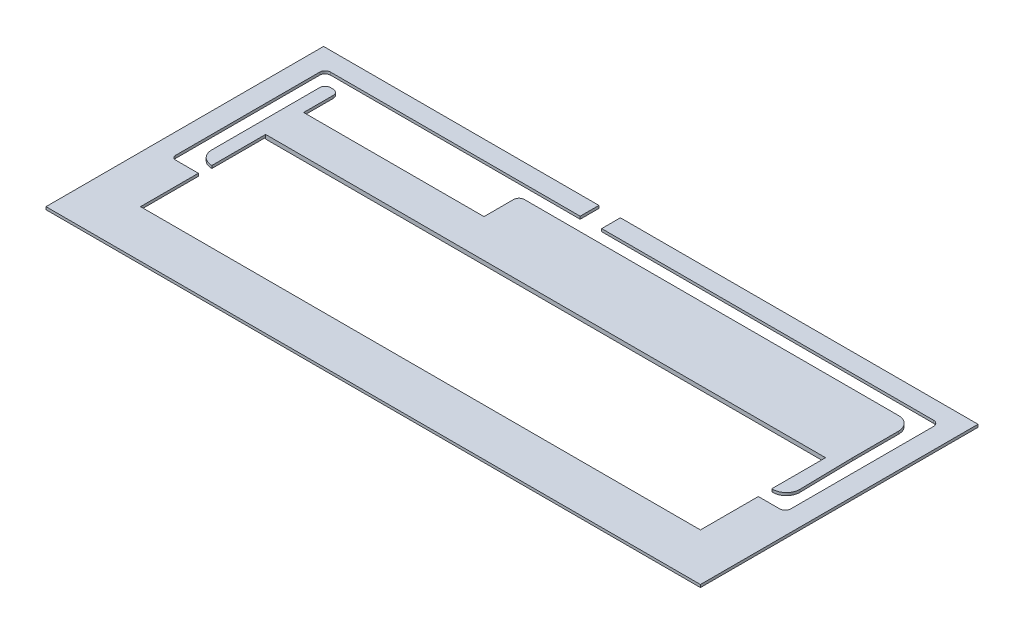
from build123d import *

# Parameters (mm, degrees)
CROQUIS1_W              = 486.2
CROQUIS1_H              = 206.2
CROQUIS1_W_2            = 480
CROQUIS1_H_2            = 200
SALIENTE_EXTRUIR1_DEPTH = 12
CROQUIS3_W              = 486.2
CROQUIS3_H              = 206.2
CROQUIS3_W_2            = 480
CROQUIS3_H_2            = 200
CORTAR_EXTRUIR1_DEPTH   = 5
CORTAR_EXTRUIR3_DEPTH   = 8
CROQUIS4_W              = 20
CROQUIS4_H              = 6
CORTAR_EXTRUIR4_DEPTH   = 3
CORTAR_EXTRUIR5_DEPTH   = 2
CROQUIS7_W              = 721.947089947
CROQUIS7_H              = 359.419856831
CORTAR_EXTRUIR6_DEPTH   = 10
CROQUIS8_W              = 416
CROQUIS8_H              = 96
CORTAR_EXTRUIR7_DEPTH   = 10
CROQUIS9_W              = 531.904745737
CROQUIS9_H              = 246.353411826
CORTAR_EXTRUIR9_DEPTH   = 10
CROQUIS10_W             = 531.904745737
CROQUIS10_H             = 246.353411826
CORTAR_EXTRUIR10_DEPTH  = 10
CROQUIS11_W             = 531.904745737
CROQUIS11_H             = 246.353411826
CORTAR_EXTRUIR11_DEPTH  = 10
CROQUIS12_W             = 416
CROQUIS12_H             = 3.047420062
SALIENTE_EXTRUIR2_DEPTH = 3


with BuildPart() as part:
    # Croquis1 → Saliente-Extruir1 (new body)
    with BuildSketch(Plane(origin=(0, 0, 0), x_dir=(1, 0, 0), z_dir=(0, 1, 0))):
        with Locations((240, 100)):
            Rectangle(CROQUIS1_W, CROQUIS1_H)
        with Locations((240, 100)):
            Rectangle(CROQUIS1_W_2, CROQUIS1_H_2, mode=Mode.SUBTRACT)
        with Locations((240, 100)):
            Rectangle(CROQUIS1_W_2, CROQUIS1_H_2)
    extrude(amount=SALIENTE_EXTRUIR1_DEPTH)

    # Croquis3 → Cortar-Extruir1 (cut)
    with BuildSketch(Plane(origin=(0, 12, 0), x_dir=(1, 0, 0), z_dir=(0, 1, 0))):
        with Locations((240, 100)):
            Rectangle(CROQUIS3_W, CROQUIS3_H)
        with Locations((240, 100)):
            Rectangle(CROQUIS3_W_2, CROQUIS3_H_2, mode=Mode.SUBTRACT)
    extrude(amount=-CORTAR_EXTRUIR1_DEPTH, mode=Mode.SUBTRACT)

    # Croquis2 → Cortar-Extruir3 (cut)
    with BuildSketch(Plane(origin=(0, 12, 0), x_dir=(1, 0, 0), z_dir=(0, 1, 0))):
        with BuildLine():
            ThreePointArc((16, 189.1902066), (13.171572875, 188.018633725), (12, 185.1902066))
            Line((12, 185.1902066), (12, 78))
            ThreePointArc((12, 78), (12.878679656, 75.878679656), (15, 75))
            Line((15, 75), (32, 75))
            Line((32, 75), (32, 32))
            Line((32, 32), (448, 32))
            Line((448, 32), (448, 75))
            Line((448, 75), (464, 75))
            ThreePointArc((464, 75), (466.828427125, 76.171572875), (468, 79))
            Line((468, 79), (468, 185.1902066))
            ThreePointArc((468, 185.1902066), (466.828427125, 188.018633725), (464, 189.1902066))
            Line((464, 189.1902066), (217.424703227, 189.1902066))
            Line((217.424703227, 189.1902066), (217.424703227, 203.1))
            Line((217.424703227, 203.1), (201.44869327, 203.1))
            Line((201.44869327, 203.1), (201.44869327, 189.1902066))
            Line((201.44869327, 189.1902066), (16, 189.1902066))
        make_face()
        with BuildLine():
            Line((32, 85), (31.963588191, 85))
            ThreePointArc((31.963588191, 85), (24.892520379, 87.928932188), (21.963588191, 95))
            Line((21.963588191, 95), (21.963588191, 175.1902066))
            ThreePointArc((21.963588191, 175.1902066), (23.135161066, 178.018633725), (25.963588191, 179.1902066))
            Line((25.963588191, 179.1902066), (28, 179.1902066))
            ThreePointArc((28, 179.1902066), (30.828427125, 178.018633725), (32, 175.1902066))
            Line((32, 175.1902066), (32, 153.1902066))
            Line((32, 153.1902066), (166, 153.1902066))
            Line((166, 153.1902066), (166, 175.1902066))
            ThreePointArc((166, 175.1902066), (167.171572875, 178.018633725), (170, 179.1902066))
            Line((170, 179.1902066), (448.036411809, 179.1902066))
            ThreePointArc((448.036411809, 179.1902066), (455.107479621, 176.261274412), (458.036411809, 169.1902066))
            Line((458.036411809, 169.1902066), (458.036411809, 135.000000034))
            Line((458.036411809, 135.000000034), (458.803569043, 95.19268186))
            ThreePointArc((458.803569043, 95.19268186), (455.944291637, 87.997386866), (448.80542553, 85))
            Line((448.80542553, 85), (448, 85))
            Line((448, 85), (448, 128))
            Line((448, 128), (32, 128))
            Line((32, 128), (32, 85))
        make_face(mode=Mode.SUBTRACT)
    extrude(amount=-CORTAR_EXTRUIR3_DEPTH, mode=Mode.SUBTRACT)

    # Croquis4 → Cortar-Extruir4 (cut)
    with BuildSketch(Plane(origin=(0, 12, 0), x_dir=(1, 0, 0), z_dir=(0, 1, 0))):
        with BuildLine():
            Line((31.963588191, 85), (32, 128))
            Line((32, 128), (32, 134))
            Line((32, 134), (32, 147.1902066))
            Line((32, 147.1902066), (32, 153.1902066))
            Line((32, 153.1902066), (32, 175.1902066))
            ThreePointArc((32, 175.1902066), (30.828427125, 178.018633725), (28, 179.1902066))
            Line((28, 179.1902066), (25.963588191, 179.1902066))
            ThreePointArc((25.963588191, 179.1902066), (23.135161066, 178.018633725), (21.963588191, 175.1902066))
            Line((21.963588191, 175.1902066), (21.963588191, 95))
            ThreePointArc((21.963588191, 95), (24.892520379, 87.928932188), (31.963588191, 85))
        make_face()
        with Locations((42, 131)):
            Rectangle(CROQUIS4_W, CROQUIS4_H)
        with Locations((42, 150.1902066)):
            Rectangle(CROQUIS4_W, CROQUIS4_H)
        with BuildLine():
            ThreePointArc((12, 78), (12.878679656, 75.878679656), (15, 75))
            Line((15, 75), (32, 75))
            Line((32, 75), (32, 69))
            Line((32, 69), (6, 69))
            Line((6, 69), (6, 80))
            Line((6, 80), (6, 195.1902066))
            Line((6, 195.1902066), (16, 195.1902066))
            Line((16, 195.1902066), (32, 195.1902066))
            Line((32, 195.1902066), (32, 189.1902066))
            Line((32, 189.1902066), (16, 189.1902066))
            ThreePointArc((16, 189.1902066), (13.171572875, 188.018633725), (12, 185.1902066))
            Line((12, 185.1902066), (12, 80))
            Line((12, 80), (12, 78))
        make_face()
        with Locations((42, 192.1902066)):
            Rectangle(CROQUIS4_W, CROQUIS4_H)
        with Locations((42, 29)):
            Rectangle(CROQUIS4_W, CROQUIS4_H)
        with Locations((156, 192.1902066)):
            Rectangle(CROQUIS4_W, CROQUIS4_H)
        with Locations((156, 150.1902066)):
            Rectangle(CROQUIS4_W, CROQUIS4_H)
        with BuildLine():
            Line((166, 147.1902066), (448, 147.1902066))
            Line((448, 147.1902066), (458.036411809, 147.1902066))
            Line((458.036411809, 147.1902066), (458.036411809, 169.1902066))
            ThreePointArc((458.036411809, 169.1902066), (455.107479621, 176.261274412), (448.036411809, 179.1902066))
            Line((448.036411809, 179.1902066), (170, 179.1902066))
            ThreePointArc((170, 179.1902066), (167.171572875, 178.018633725), (166, 175.1902066))
            Line((166, 175.1902066), (166, 153.1902066))
            Line((166, 153.1902066), (166, 147.1902066))
        make_face()
        with BuildLine():
            Line((458.036411809, 169.1902066), (458.036411809, 147.1902066))
            Line((458.036411809, 147.1902066), (474, 147.1902066))
            Line((474, 147.1902066), (474, 195.1902066))
            Line((474, 195.1902066), (166, 195.1902066))
            Line((166, 195.1902066), (166, 189.1902066))
            Line((166, 189.1902066), (166, 175.1902066))
            ThreePointArc((166, 175.1902066), (167.171572875, 178.018633725), (170, 179.1902066))
            Line((170, 179.1902066), (448.036411809, 179.1902066))
            ThreePointArc((448.036411809, 179.1902066), (455.107479621, 176.261274412), (458.036411809, 169.1902066))
        make_face()
        with BuildLine():
            Line((448.80542553, 85), (448, 85))
            Line((448, 85), (448, 69))
            Line((448, 69), (474, 69))
            Line((474, 69), (474, 147.1902066))
            Line((474, 147.1902066), (458.036411809, 147.1902066))
            Line((458.036411809, 147.1902066), (458.036411809, 135.000000034))
            Line((458.036411809, 135.000000034), (458.803569043, 95.19268186))
            ThreePointArc((458.803569043, 95.19268186), (455.944291637, 87.997386866), (448.80542553, 85))
        make_face()
        with Locations((438, 131)):
            Rectangle(CROQUIS4_W, CROQUIS4_H)
        with Locations((438, 29)):
            Rectangle(CROQUIS4_W, CROQUIS4_H)
        with BuildLine():
            Line((448, 134), (448, 128))
            Line((448, 128), (448, 85))
            Line((448, 85), (448.80542553, 85))
            ThreePointArc((448.80542553, 85), (455.944291637, 87.997386866), (458.803569043, 95.19268186))
            Line((458.803569043, 95.19268186), (458.036411809, 135.000000034))
            Line((458.036411809, 135.000000034), (458.036411809, 147.1902066))
            Line((458.036411809, 147.1902066), (448, 147.1902066))
            Line((448, 147.1902066), (448, 134))
        make_face()
    extrude(amount=-CORTAR_EXTRUIR4_DEPTH, mode=Mode.SUBTRACT)

    # Croquis5 → Cortar-Extruir5 (cut)
    with BuildSketch(Plane(origin=(0, 4, 0), x_dir=(1, 0, 0), z_dir=(0, 1, 0))):
        with BuildLine():
            Line((32.046028397, 84.926485337), (32, 75))
            Line((32, 75), (15, 75))
            ThreePointArc((15, 75), (12.878679656, 75.878679656), (12, 78))
            Line((12, 78), (12, 185.1902066))
            ThreePointArc((12, 185.1902066), (13.171572875, 188.018633725), (16, 189.1902066))
            Line((16, 189.1902066), (201.44869327, 189.1902066))
            Line((201.44869327, 189.1902066), (201.44869327, 203.1))
            Line((201.44869327, 203.1), (217.424703227, 203.1))
            Line((217.424703227, 203.1), (217.424703227, 189.1902066))
            Line((217.424703227, 189.1902066), (464, 189.1902066))
            ThreePointArc((464, 189.1902066), (466.828427125, 188.018633725), (468, 185.1902066))
            Line((468, 185.1902066), (468, 79))
            ThreePointArc((468, 79), (466.828427125, 76.171572875), (464, 75))
            Line((464, 75), (448, 75))
            Line((448, 75), (448, 85))
            Line((448, 85), (448.80542553, 85))
            ThreePointArc((448.80542553, 85), (455.917657262, 88.023512896), (458.803569043, 95.19268186))
            Line((458.803569043, 95.19268186), (458.036411809, 169.1902066))
            ThreePointArc((458.036411809, 169.1902066), (455.107479621, 176.261274412), (448.036411809, 179.1902066))
            Line((448.036411809, 179.1902066), (170, 179.1902066))
            ThreePointArc((170, 179.1902066), (167.171572875, 178.018633725), (166, 175.1902066))
            Line((166, 175.1902066), (166, 153.1902066))
            Line((166, 153.1902066), (32, 153.1902066))
            Line((32, 153.1902066), (32, 175.1902066))
            ThreePointArc((32, 175.1902066), (30.828427125, 178.018633725), (28, 179.1902066))
            Line((28, 179.1902066), (25.963588191, 179.1902066))
            ThreePointArc((25.963588191, 179.1902066), (23.135161066, 178.018633725), (21.963588191, 175.1902066))
            Line((21.963588191, 175.1902066), (21.963588191, 95))
            ThreePointArc((21.963588191, 95), (24.91720844, 87.873793117), (32.046028397, 84.926485337))
        make_face()
    extrude(amount=-CORTAR_EXTRUIR5_DEPTH, mode=Mode.SUBTRACT)

    # Croquis7 → Cortar-Extruir6 (cut)
    with BuildSketch(Plane(origin=(0, 2, 0), x_dir=(1, 0, 0), z_dir=(0, 1, 0))):
        with Locations((149.368191722, 161.470369199)):
            Rectangle(CROQUIS7_W, CROQUIS7_H)
    extrude(amount=-CORTAR_EXTRUIR6_DEPTH, mode=Mode.SUBTRACT)

    # Croquis8 → Cortar-Extruir7 (cut)
    with BuildSketch(Plane(origin=(0, 4, 0), x_dir=(1, 0, 0), z_dir=(0, 1, 0))):
        with Locations((240, 80)):
            Rectangle(CROQUIS8_W, CROQUIS8_H)
    extrude(amount=-CORTAR_EXTRUIR7_DEPTH, mode=Mode.SUBTRACT)


with BuildPart() as cortar_extruir7_piece_1:
    # of the separate pieces the step leaves, piece 1, a body of its own (cortar_extruir7_pieces)
    add(part.part.solids().sort_by_distance((483.1, 2, 3.1))[0])


with BuildPart() as cortar_extruir7_piece_2:
    # of the separate pieces the step leaves, piece 2, a body of its own (cortar_extruir7_pieces)
    add(part.part.solids().sort_by_distance((32, 2, -128))[0])


with BuildPart() as cortar_extruir9_tool:
    # Croquis9 → Cortar-Extruir9 (new body)
    with BuildSketch(Plane(origin=(0, 9, 0), x_dir=(1, 0, 0), z_dir=(0, 1, 0))):
        with Locations((247.004349215, 106.418772052)):
            Rectangle(CROQUIS9_W, CROQUIS9_H)
    extrude(amount=CORTAR_EXTRUIR9_DEPTH)


with BuildPart() as cortar_extruir7_piece_1_1:
    add(cortar_extruir7_piece_1.part)

    # Cortar-Extruir9: cut by cortar_extruir9_tool
    add(cortar_extruir9_tool.part, mode=Mode.SUBTRACT)


with BuildPart() as cortar_extruir7_piece_2_1:
    add(cortar_extruir7_piece_2.part)

    # Cortar-Extruir9: cut by cortar_extruir9_tool
    add(cortar_extruir9_tool.part, mode=Mode.SUBTRACT)


with BuildPart() as cortar_extruir10_tool:
    # Croquis10 → Cortar-Extruir10 (new body)
    with BuildSketch(Plane(origin=(0, 7, 0), x_dir=(1, 0, 0), z_dir=(0, 1, 0))):
        with Locations((247.004349215, 106.418772052)):
            Rectangle(CROQUIS10_W, CROQUIS10_H)
    extrude(amount=CORTAR_EXTRUIR10_DEPTH)


with BuildPart() as cortar_extruir7_piece_1_2:
    add(cortar_extruir7_piece_1_1.part)

    # Cortar-Extruir10: cut by cortar_extruir10_tool
    add(cortar_extruir10_tool.part, mode=Mode.SUBTRACT)


with BuildPart() as cortar_extruir7_piece_2_2:
    add(cortar_extruir7_piece_2_1.part)

    # Cortar-Extruir10: cut by cortar_extruir10_tool
    add(cortar_extruir10_tool.part, mode=Mode.SUBTRACT)


with BuildPart() as cortar_extruir11_tool:
    # Croquis11 → Cortar-Extruir11 (new body)
    with BuildSketch(Plane(origin=(0, 5, 0), x_dir=(-1, 0, 0), z_dir=(0, -1, 0))):
        with Locations((-247.004349215, 106.418772052)):
            Rectangle(CROQUIS11_W, CROQUIS11_H)
    extrude(amount=CORTAR_EXTRUIR11_DEPTH)


with BuildPart() as cortar_extruir7_piece_1_3:
    add(cortar_extruir7_piece_1_2.part)

    # Cortar-Extruir11: cut by cortar_extruir11_tool
    add(cortar_extruir11_tool.part, mode=Mode.SUBTRACT)


with BuildPart() as cortar_extruir7_piece_2_3:
    add(cortar_extruir7_piece_2_2.part)

    # Cortar-Extruir11: cut by cortar_extruir11_tool
    add(cortar_extruir11_tool.part, mode=Mode.SUBTRACT)

    # Croquis12 → Saliente-Extruir2 (add)
    with BuildSketch(Plane(origin=(0, 7, 0), x_dir=(1, 0, 0), z_dir=(0, 1, 0))):
        with Locations((240, 126.476289969)):
            Rectangle(CROQUIS12_W, CROQUIS12_H)
    extrude(amount=-SALIENTE_EXTRUIR2_DEPTH)


solid = Compound([cortar_extruir7_piece_1_3.part, cortar_extruir7_piece_2_3.part])
